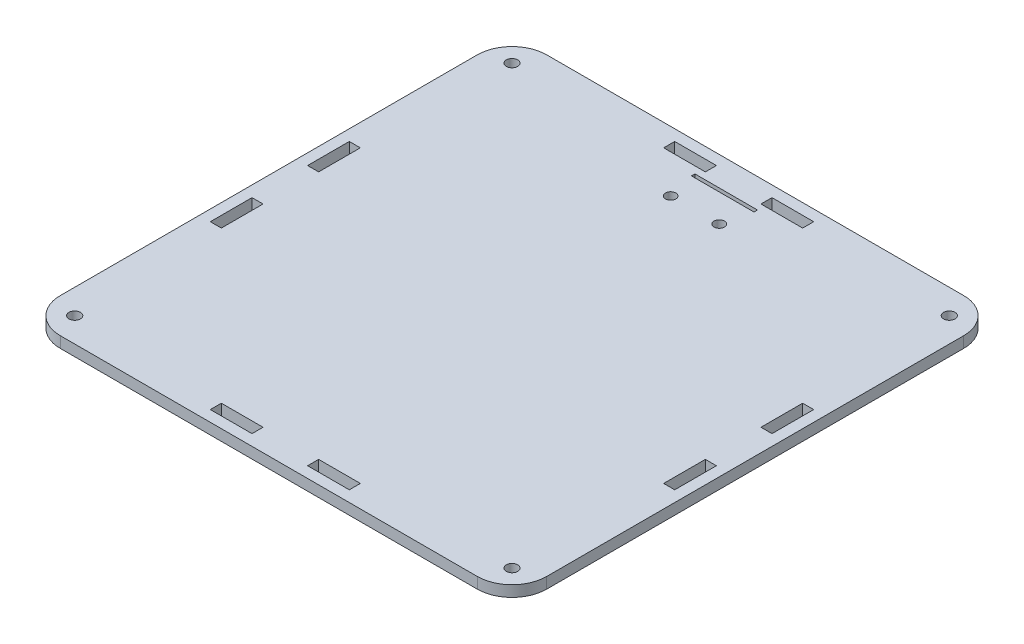
from build123d import *

# Parameters (mm, degrees)
SKETCH1_W           = 140
SKETCH1_H           = 140
SKETCH1_R           = 1.65
SKETCH1_R_2         = 1.5
SKETCH1_W_2         = 3.175
SKETCH1_H_2         = 12
SKETCH1_W_3         = 12
SKETCH1_H_3         = 3.175
SKETCH1_W_4         = 18
SKETCH1_H_4         = 1
BOSS_EXTRUDE1_DEPTH = 3.175
FILLET1_R           = 10


with BuildPart() as part:
    # Sketch1 → Boss-Extrude1 (new body)
    with BuildSketch(Plane(origin=(0, 0, 0), x_dir=(1, 0, 0), z_dir=(0, 1, 0))):
        Rectangle(SKETCH1_W, SKETCH1_H)
        with Locations((62.928932188, -62.928932188)):
            Circle(SKETCH1_R, mode=Mode.SUBTRACT)
        with Locations((62.928932188, 62.928932188)):
            Circle(SKETCH1_R, mode=Mode.SUBTRACT)
        with Locations((-62.928932188, -62.928932188)):
            Circle(SKETCH1_R, mode=Mode.SUBTRACT)
        with Locations((-62.928932188, 62.928932188)):
            Circle(SKETCH1_R, mode=Mode.SUBTRACT)
        with Locations((7, 52.65)):
            Circle(SKETCH1_R_2, mode=Mode.SUBTRACT)
        with Locations((-7, 52.65)):
            Circle(SKETCH1_R_2, mode=Mode.SUBTRACT)
        with Locations((-65.2375, -14)):
            Rectangle(SKETCH1_W_2, SKETCH1_H_2, mode=Mode.SUBTRACT)
        with Locations((65.2375, -14)):
            Rectangle(SKETCH1_W_2, SKETCH1_H_2, mode=Mode.SUBTRACT)
        with Locations((14, -65.2375)):
            Rectangle(SKETCH1_W_3, SKETCH1_H_3, mode=Mode.SUBTRACT)
        with Locations((-14, -65.2375)):
            Rectangle(SKETCH1_W_3, SKETCH1_H_3, mode=Mode.SUBTRACT)
        with Locations((65.2375, 14)):
            Rectangle(SKETCH1_W_2, SKETCH1_H_2, mode=Mode.SUBTRACT)
        with Locations((14, 65.2375)):
            Rectangle(SKETCH1_W_3, SKETCH1_H_3, mode=Mode.SUBTRACT)
        with Locations((-14, 65.2375)):
            Rectangle(SKETCH1_W_3, SKETCH1_H_3, mode=Mode.SUBTRACT)
        with Locations((-65.2375, 14)):
            Rectangle(SKETCH1_W_2, SKETCH1_H_2, mode=Mode.SUBTRACT)
        with Locations((0, 61.15)):
            Rectangle(SKETCH1_W_4, SKETCH1_H_4, mode=Mode.SUBTRACT)
    extrude(amount=BOSS_EXTRUDE1_DEPTH)

    # Fillet1
    fillet1_edges = [part.edges().sort_by_distance(p)[0] for p in [
        (70, 1.5875, 70),
        (-70, 1.5875, 70),
        (-70, 1.5875, -70),
        (70, 1.5875, -70),
    ]]
    fillet(fillet1_edges, radius=FILLET1_R)


solid = part.part
